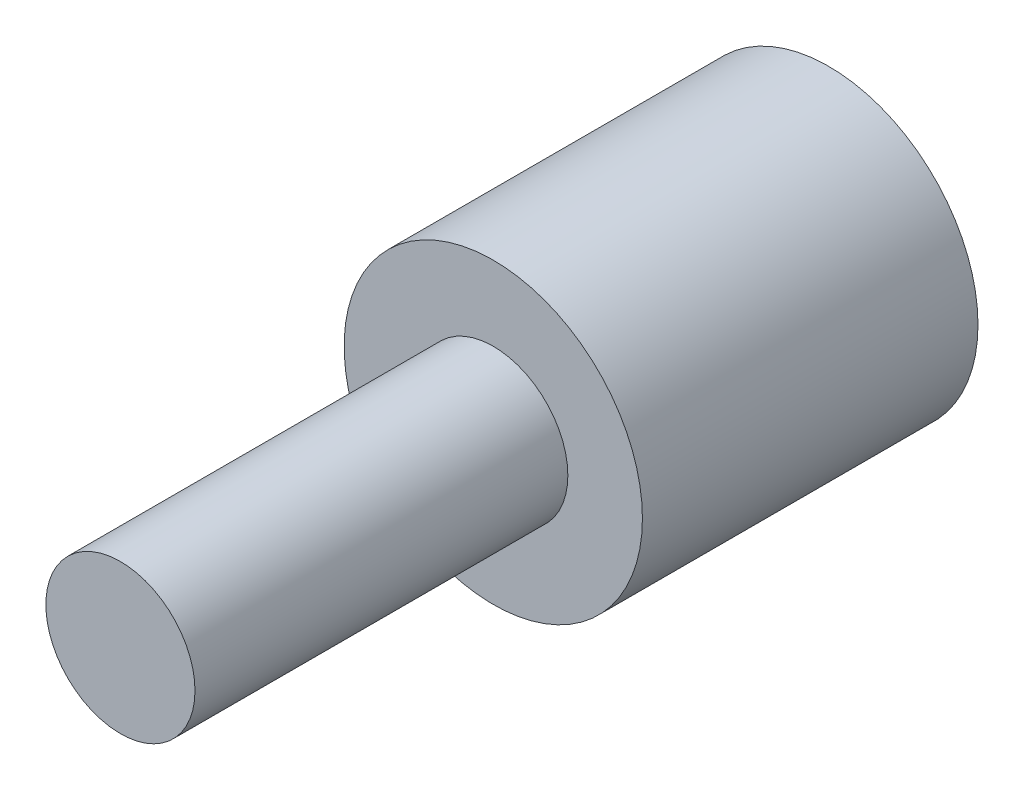
from build123d import *


with BuildPart() as part:
    # Skizze1 → Grundk_rper (revolve)
    with BuildSketch(Plane(origin=(0, 0, 0), x_dir=(0, 0, -1), z_dir=(1, 0, 0)), mode=Mode.PRIVATE) as grundk_rper_sk:
        Polygon((95, 0), (95, 20), (50, 20), (50, 10), (0, 10), (0, 0), align=None)
    revolve(grundk_rper_sk.sketch.rotate(Axis((0, 0, 0), (0, 0, -1)), 90), axis=Axis((0, 0, 0), (0, 0, -1)))  # turned: the seam where the file's is


solid = part.part
